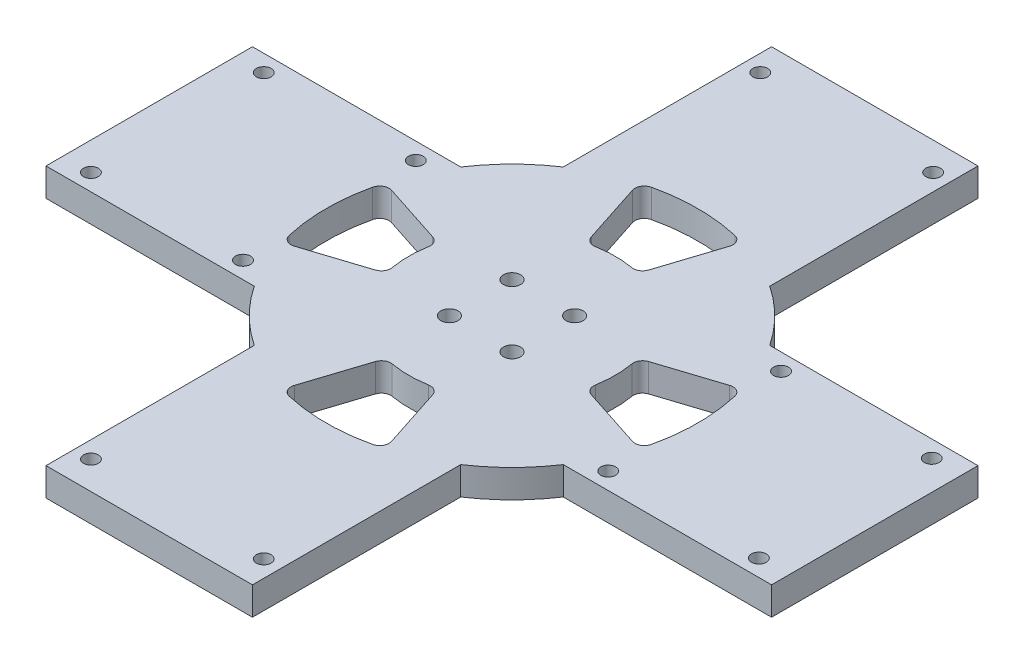
from build123d import *

# Parameters (mm, degrees)
BOSS_EXTRUDE1_DEPTH             = 4.763
M2_5_CLEARANCE_HOLE1_D          = 2.9
TAP_DRILL_FOR_M3X0_5_TAP1_D     = 2.5
TAP_DRILL_FOR_M3X0_5_TAP1_DEPTH = 4.763


with BuildPart() as part:
    # Sketch1 → Boss-Extrude1 (new body)
    with BuildSketch(Plane(origin=(0, 0, 0), x_dir=(1, 0, 0), z_dir=(0, 1, 0))):
        with BuildLine():
            Line((-61.5, 17.5), (-26.191601707, 17.5))
            ThreePointArc((-26.191601707, 17.5), (-22.273863607, 22.273863607), (-17.5, 26.191601707))
            Line((-17.5, 26.191601707), (-17.5, 61.5))
            Line((-17.5, 61.5), (17.5, 61.5))
            Line((17.5, 61.5), (17.5, 26.191601707))
            ThreePointArc((17.5, 26.191601707), (22.273863607, 22.273863607), (26.191601707, 17.5))
            Line((26.191601707, 17.5), (61.5, 17.5))
            Line((61.5, 17.5), (61.5, -17.5))
            Line((61.5, -17.5), (26.191601707, -17.5))
            ThreePointArc((26.191601707, -17.5), (22.273863607, -22.273863607), (17.5, -26.191601707))
            Line((17.5, -26.191601707), (17.5, -61.5))
            Line((17.5, -61.5), (-17.5, -61.5))
            Line((-17.5, -61.5), (-17.5, -26.191601707))
            ThreePointArc((-17.5, -26.191601707), (-22.273863607, -22.273863607), (-26.191601707, -17.5))
            Line((-26.191601707, -17.5), (-61.5, -17.5))
            Line((-61.5, -17.5), (-61.5, 17.5))
        make_face()
        with BuildLine():
            Line((-18.299951333, 4.863661227), (-28.657445997, 8.22916814))
            ThreePointArc((-28.657445997, 8.22916814), (-29.929968402, 8.100940268), (-30.69495913, 7.075979368))
            ThreePointArc((-30.69495913, 7.075979368), (-31.5, 0), (-30.69495913, -7.075979368))
            ThreePointArc((-30.69495913, -7.075979368), (-29.929968402, -8.100940268), (-28.657445997, -8.22916814))
            Line((-28.657445997, -8.22916814), (-18.299951333, -4.863661227))
            ThreePointArc((-18.299951333, -4.863661227), (-17.4289221, -4.170054209), (-17.227734354, -3.074925855))
            ThreePointArc((-17.227734354, -3.074925855), (-17.5, 0), (-17.227734354, 3.074925855))
            ThreePointArc((-17.227734354, 3.074925855), (-17.4289221, 4.170054209), (-18.299951333, 4.863661227))
        make_face(mode=Mode.SUBTRACT)
        with BuildLine():
            Line((-4.863661227, 18.299951333), (-8.22916814, 28.657445997))
            ThreePointArc((-8.22916814, 28.657445997), (-8.100940268, 29.929968402), (-7.075979368, 30.69495913))
            ThreePointArc((-7.075979368, 30.69495913), (0, 31.5), (7.075979368, 30.69495913))
            ThreePointArc((7.075979368, 30.69495913), (8.100940268, 29.929968402), (8.22916814, 28.657445997))
            Line((8.22916814, 28.657445997), (4.863661227, 18.299951333))
            ThreePointArc((4.863661227, 18.299951333), (4.170054209, 17.4289221), (3.074925855, 17.227734354))
            ThreePointArc((3.074925855, 17.227734354), (0, 17.5), (-3.074925855, 17.227734354))
            ThreePointArc((-3.074925855, 17.227734354), (-4.170054209, 17.4289221), (-4.863661227, 18.299951333))
        make_face(mode=Mode.SUBTRACT)
        with BuildLine():
            Line((18.299951333, 4.863661227), (28.657445997, 8.22916814))
            ThreePointArc((28.657445997, 8.22916814), (29.929968402, 8.100940268), (30.69495913, 7.075979368))
            ThreePointArc((30.69495913, 7.075979368), (31.5, 0), (30.69495913, -7.075979368))
            ThreePointArc((30.69495913, -7.075979368), (29.929968402, -8.100940268), (28.657445997, -8.22916814))
            Line((28.657445997, -8.22916814), (18.299951333, -4.863661227))
            ThreePointArc((18.299951333, -4.863661227), (17.4289221, -4.170054209), (17.227734354, -3.074925855))
            ThreePointArc((17.227734354, -3.074925855), (17.5, 0), (17.227734354, 3.074925855))
            ThreePointArc((17.227734354, 3.074925855), (17.4289221, 4.170054209), (18.299951333, 4.863661227))
        make_face(mode=Mode.SUBTRACT)
        with BuildLine():
            Line((4.863661227, -18.299951333), (8.22916814, -28.657445997))
            ThreePointArc((8.22916814, -28.657445997), (8.100940268, -29.929968402), (7.075979368, -30.69495913))
            ThreePointArc((7.075979368, -30.69495913), (0, -31.5), (-7.075979368, -30.69495913))
            ThreePointArc((-7.075979368, -30.69495913), (-8.100940268, -29.929968402), (-8.22916814, -28.657445997))
            Line((-8.22916814, -28.657445997), (-4.863661227, -18.299951333))
            ThreePointArc((-4.863661227, -18.299951333), (-4.170054209, -17.4289221), (-3.074925855, -17.227734354))
            ThreePointArc((-3.074925855, -17.227734354), (0, -17.5), (3.074925855, -17.227734354))
            ThreePointArc((3.074925855, -17.227734354), (4.170054209, -17.4289221), (4.863661227, -18.299951333))
        make_face(mode=Mode.SUBTRACT)
    extrude(amount=BOSS_EXTRUDE1_DEPTH)

    # M2.5 Clearance Hole1 (through all)
    with Locations(Plane(origin=(0, 4.763, 0), x_dir=(1, 0, 0), z_dir=(0, 1, 0))):
        with Locations((5.303300859, 5.303300859), (-5.303300859, 5.303300859), (-5.303300859, -5.303300859), (5.303300859, -5.303300859)):
            Hole(M2_5_CLEARANCE_HOLE1_D / 2)

    # Tap Drill for M3x0.5 Tap1
    with Locations(Plane(origin=(0, 4.763, 0), x_dir=(1, 0, 0), z_dir=(0, 1, 0))):
        with Locations((-56.7375, 14.65), (-30.954101707, 14.65), (-56.7375, -14.65), (30.954101707, 14.65), (56.5, 14.65), (-30.954101707, -14.65), (30.954101707, -14.65), (56.5, -14.65), (-14.65, 56.7375), (14.65, 56.7375), (-14.65, -56.7375), (14.65, -56.7375)):
            Hole(TAP_DRILL_FOR_M3X0_5_TAP1_D / 2, depth=TAP_DRILL_FOR_M3X0_5_TAP1_DEPTH)


solid = part.part
